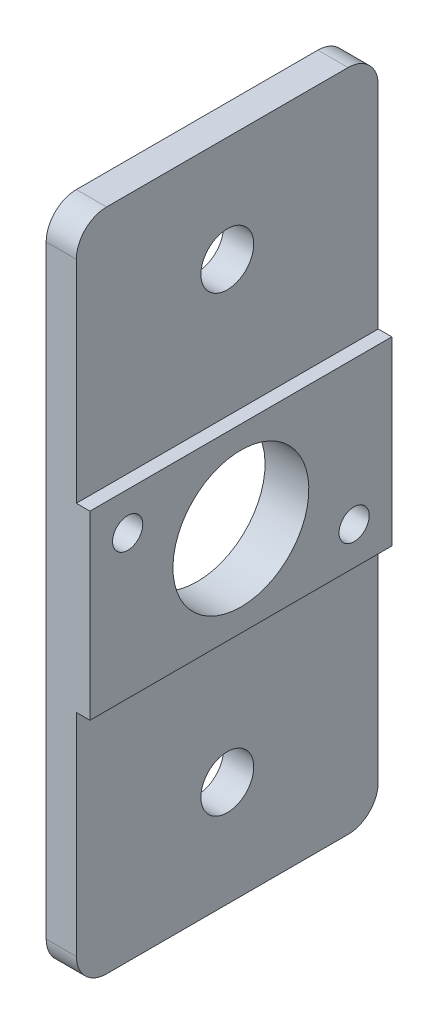
from build123d import *

# Parameters (mm, degrees)
BOSS_EXTRUDE1_DEPTH = 20
SKETCH2_R           = 1.75
SKETCH2_R_2         = 4.5
CUT_EXTRUDE1_DEPTH  = 3.9
SKETCH3_R           = 1
CUT_EXTRUDE2_DEPTH  = 1.8
FILLET1_R           = 2


with BuildPart() as part:
    # Sketch1 → Boss-Extrude1 (new body)
    with BuildSketch(Plane.XY):
        Polygon((0, 0), (0, -44), (2, -44), (2, -28), (2.9, -28), (2.9, -16), (2, -16), (2, 0), align=None)
    extrude(amount=BOSS_EXTRUDE1_DEPTH)

    # Sketch2 → Cut-Extrude1 (cut, through all)
    with BuildSketch(Plane.ZY):
        with Locations((10, -7)):
            Circle(SKETCH2_R)
        with Locations((10, -37)):
            Circle(SKETCH2_R)
        with Locations((10, -22)):
            Circle(SKETCH2_R_2)
    extrude(amount=-CUT_EXTRUDE1_DEPTH, mode=Mode.SUBTRACT)

    # Sketch3 → Cut-Extrude2 (cut)
    with BuildSketch(Plane(origin=(2.9, 0, 0), x_dir=(0, 0, -1), z_dir=(1, 0, 0))):
        with Locations((-17.5, -18.5)):
            Circle(SKETCH3_R)
        with Locations((-2.5, -25.5)):
            Circle(SKETCH3_R)
    extrude(amount=-CUT_EXTRUDE2_DEPTH, mode=Mode.SUBTRACT)

    # Fillet1
    fillet1_edges = [part.edges().sort_by_distance(p)[0] for p in [
        (1, -44, 20),
        (1, 0, 0),
        (1, 0, 20),
        (1, -44, 0),
    ]]
    fillet(fillet1_edges, radius=FILLET1_R)


solid = part.part
